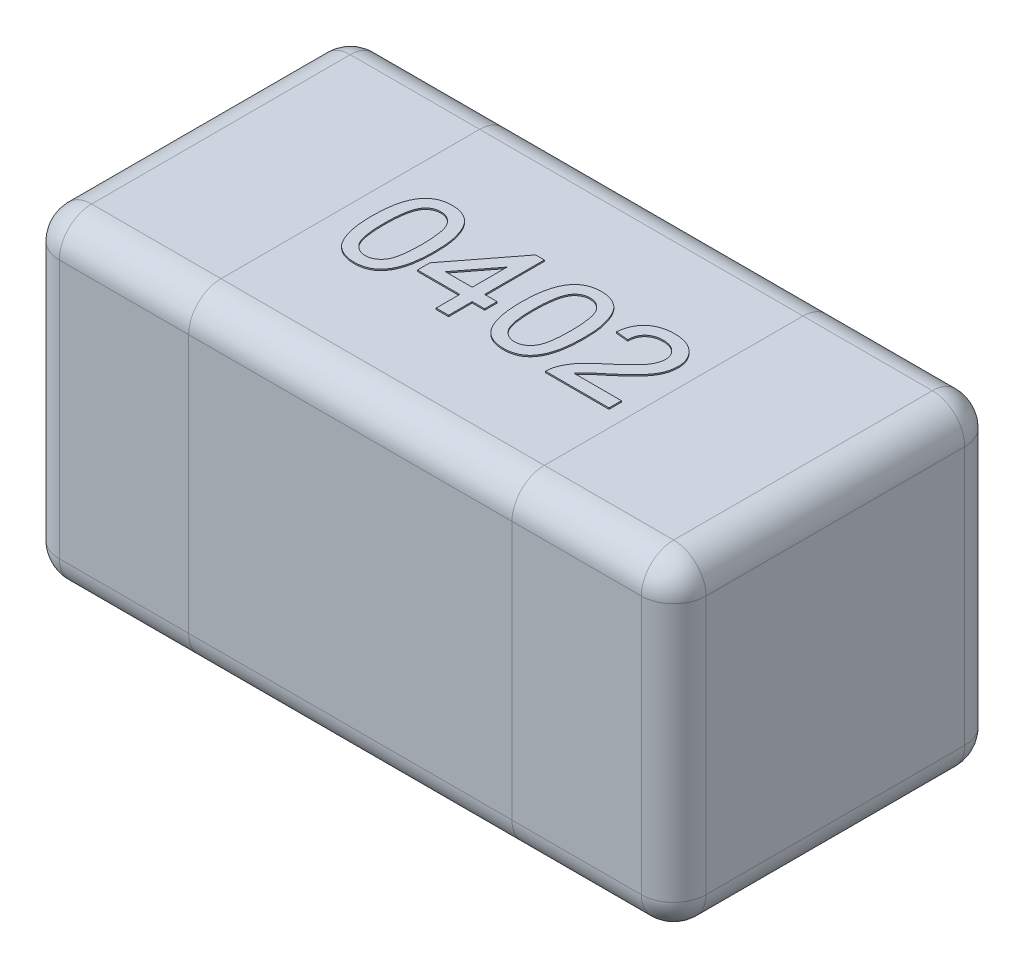
from build123d import *

# Parameters (mm, degrees)
SKETCH1_W      = 1
SKETCH1_H      = 0.5
EXTRUDE1_DEPTH = 0.5
FILLET1_R      = 0.05
EXTRUDE2_DEPTH = 0.002


with BuildPart() as part:
    # Sketch1 → Extrude1 (new body)
    with BuildSketch(Plane(origin=(0, 0, 0), x_dir=(1, 0, 0), z_dir=(0, 1, 0))):
        Rectangle(SKETCH1_W, SKETCH1_H)
    extrude(amount=EXTRUDE1_DEPTH)

    # Fillet1
    fillet1_edges = [part.edges().sort_by_distance(p)[0] for p in [
        (-0.5, 0.25, -0.25),
        (0.5, 0.25, -0.25),
        (0, 0, -0.25),
        (0, 0.5, -0.25),
        (0.5, 0.25, 0.25),
        (0.5, 0, 0),
        (0.5, 0.5, 0),
        (-0.5, 0.25, 0.25),
        (0, 0, 0.25),
        (0, 0.5, 0.25),
        (-0.5, 0, 0),
        (-0.5, 0.5, 0),
    ]]
    fillet(fillet1_edges, radius=FILLET1_R)

    # Sketch3 → Extrude2 (add)
    with BuildSketch(Plane(origin=(0, 0.5, 0), x_dir=(1, 0, 0), z_dir=(0, 1, 0))):
        with BuildLine():
            add(Edge.make_bspline(
                [(-0.215384615, -0.001021635), (-0.21536524, 0.001122003), (-0.215327293, 0.005320487), (-0.215091917, 0.011463622), (-0.21468097, 0.017297504), (-0.214067539, 0.022817065), (-0.213341122, 0.028034764), (-0.212396775, 0.032943155), (-0.211334247, 0.037553251), (-0.210059405, 0.041860246), (-0.20865877, 0.045901174), (-0.207069705, 0.04966955), (-0.205281792, 0.053161381), (-0.203382895, 0.056412877), (-0.201273053, 0.059373466), (-0.19907961, 0.062126232), (-0.196643162, 0.064570222), (-0.19406502, 0.06676832), (-0.191307221, 0.068708013), (-0.188384356, 0.070381735), (-0.185307672, 0.07185951), (-0.182018531, 0.072971978), (-0.178585214, 0.073878876), (-0.174981294, 0.074546001), (-0.171202799, 0.074939294), (-0.168620729, 0.074979536), (-0.167307692, 0.075)],
                knots=[0, 0, 0, 0, 6.431e-06, 1.2595e-05, 1.844e-05, 2.3971e-05, 2.9254e-05, 3.4239e-05, 3.8962e-05, 4.344e-05, 4.7707e-05, 5.1787e-05, 5.5698e-05, 5.947e-05, 6.3071e-05, 6.6596e-05, 7.0016e-05, 7.3406e-05, 7.6749e-05, 8.0114e-05, 8.3502e-05, 8.697e-05, 9.0512e-05, 9.4149e-05, 9.7955e-05, 0.000101893, 0.000101893, 0.000101893, 0.000101893], degree=3))
            add(Edge.make_bspline(
                [(-0.167307692, 0.075), (-0.165381297, 0.074943365), (-0.161596815, 0.074832104), (-0.156071453, 0.073924679), (-0.150864154, 0.072372388), (-0.145978304, 0.070278281), (-0.141497424, 0.067618363), (-0.137495809, 0.064384826), (-0.134016624, 0.060611623), (-0.131097837, 0.056254042), (-0.128546526, 0.051432296), (-0.126279998, 0.046124741), (-0.124231122, 0.040337325), (-0.122777195, 0.035156781), (-0.12174011, 0.030684751), (-0.121053643, 0.026996347), (-0.120483737, 0.023016538), (-0.120047112, 0.018754953), (-0.119688871, 0.014216372), (-0.119412219, 0.009397968), (-0.119271789, 0.004287698), (-0.119244699, 0.000781321), (-0.119230769, -0.001021635)],
                knots=[0, 0, 0, 0, 5.777e-06, 1.1349e-05, 1.674e-05, 2.2043e-05, 2.7258e-05, 3.2321e-05, 3.7425e-05, 4.2592e-05, 4.801e-05, 5.377e-05, 5.9891e-05, 6.6416e-05, 6.99e-05, 7.366e-05, 7.7668e-05, 8.1958e-05, 8.651e-05, 9.1325e-05, 9.6435e-05, 0.000101844, 0.000101844, 0.000101844, 0.000101844], degree=3))
            add(Edge.make_bspline(
                [(-0.119230769, -0.001021635), (-0.119250507, -0.003155203), (-0.119289069, -0.00732355), (-0.119518138, -0.013417428), (-0.119953848, -0.019207296), (-0.120489996, -0.024706416), (-0.121301077, -0.029900109), (-0.12217506, -0.034810441), (-0.123255962, -0.039415115), (-0.12451712, -0.043716149), (-0.12593747, -0.047736285), (-0.127495104, -0.051505906), (-0.129220334, -0.055022436), (-0.131164508, -0.058251575), (-0.133238671, -0.061236186), (-0.135458016, -0.063987464), (-0.137869594, -0.066465811), (-0.140470969, -0.068657315), (-0.143209405, -0.070631406), (-0.146139376, -0.072321652), (-0.149248057, -0.073721992), (-0.152514679, -0.074919212), (-0.155972386, -0.075796465), (-0.159593911, -0.076467989), (-0.163392598, -0.07686343), (-0.165984655, -0.07690292), (-0.167307692, -0.076923077)],
                knots=[0, 0, 0, 0, 6.401e-06, 1.2505e-05, 1.829e-05, 2.3818e-05, 2.9075e-05, 3.4055e-05, 3.8778e-05, 4.3256e-05, 4.7495e-05, 5.1563e-05, 5.5487e-05, 5.9233e-05, 6.2859e-05, 6.6384e-05, 6.9826e-05, 7.3215e-05, 7.6576e-05, 7.9941e-05, 8.3343e-05, 8.6794e-05, 9.0365e-05, 9.4031e-05, 9.7837e-05, 0.000101805, 0.000101805, 0.000101805, 0.000101805], degree=3))
            add(Edge.make_bspline(
                [(-0.167307692, -0.076923077), (-0.169042347, -0.076873596), (-0.172424447, -0.076777121), (-0.177363754, -0.076121636), (-0.181999557, -0.074967951), (-0.186370957, -0.073420697), (-0.190428817, -0.071351156), (-0.194192513, -0.068833154), (-0.197737673, -0.065925277), (-0.199778482, -0.063631029), (-0.200811298, -0.062469952)],
                knots=[0, 0, 0, 0, 5.204e-06, 1.0146e-05, 1.4912e-05, 1.9513e-05, 2.4028e-05, 2.8537e-05, 3.308e-05, 3.7736e-05, 3.7736e-05, 3.7736e-05, 3.7736e-05], degree=3))
            add(Edge.make_bspline(
                [(-0.200811298, -0.062469952), (-0.202000093, -0.060755098), (-0.204451439, -0.057218995), (-0.207320527, -0.051189611), (-0.209879805, -0.044552107), (-0.211888368, -0.037176254), (-0.213461574, -0.029120757), (-0.214597822, -0.020369808), (-0.215240826, -0.010927188), (-0.215335604, -0.004398023), (-0.215384615, -0.001021635)],
                knots=[0, 0, 0, 0, 6.251e-06, 1.2889e-05, 1.9965e-05, 2.7576e-05, 3.5785e-05, 4.4573e-05, 5.4032e-05, 6.4161e-05, 6.4161e-05, 6.4161e-05, 6.4161e-05], degree=3))
        make_face()
        with BuildLine():
            add(Edge.make_bspline(
                [(-0.196153846, -0.000961538), (-0.196134752, -0.003846584), (-0.1960982, -0.009369199), (-0.195716327, -0.017259208), (-0.195058949, -0.024377073), (-0.194189852, -0.030712939), (-0.193042293, -0.036275377), (-0.191601396, -0.041050211), (-0.189977162, -0.045094751), (-0.187967204, -0.048358867), (-0.185766521, -0.051019598), (-0.183494467, -0.053307912), (-0.181097587, -0.055252927), (-0.178591522, -0.056874673), (-0.175937387, -0.058102553), (-0.173164205, -0.058992522), (-0.170271373, -0.059504686), (-0.168301222, -0.059578275), (-0.167307692, -0.059615385)],
                knots=[0, 0, 0, 0, 8.655e-06, 1.6567e-05, 2.3689e-05, 3.0093e-05, 3.5745e-05, 4.0706e-05, 4.5043e-05, 4.8779e-05, 5.2153e-05, 5.5383e-05, 5.8438e-05, 6.1397e-05, 6.4314e-05, 6.7184e-05, 7.0113e-05, 7.3094e-05, 7.3094e-05, 7.3094e-05, 7.3094e-05], degree=3))
            add(Edge.make_bspline(
                [(-0.167307692, -0.059615385), (-0.166314411, -0.059577464), (-0.164344754, -0.059502268), (-0.161445238, -0.059001397), (-0.158682846, -0.058065613), (-0.156032668, -0.05684207), (-0.153508388, -0.055257289), (-0.15112328, -0.053304927), (-0.148839257, -0.051017971), (-0.14664846, -0.048326314), (-0.144653815, -0.045047107), (-0.142999112, -0.041005862), (-0.141580671, -0.036222665), (-0.140426814, -0.030663062), (-0.139554132, -0.024337213), (-0.138900728, -0.01723909), (-0.1385163, -0.009359233), (-0.138480352, -0.003846597), (-0.138461538, -0.000961538)],
                knots=[0, 0, 0, 0, 2.98e-06, 5.91e-06, 8.789e-06, 1.1706e-05, 1.4649e-05, 1.7704e-05, 2.0934e-05, 2.4331e-05, 2.8093e-05, 3.2402e-05, 3.7392e-05, 4.3044e-05, 4.9418e-05, 5.654e-05, 6.4422e-05, 7.3077e-05, 7.3077e-05, 7.3077e-05, 7.3077e-05], degree=3))
            add(Edge.make_bspline(
                [(-0.138461538, -0.000961538), (-0.13847975, 0.001863491), (-0.138514642, 0.007276142), (-0.138908985, 0.015014149), (-0.139526956, 0.022012544), (-0.140372243, 0.028277777), (-0.141495628, 0.033803048), (-0.142858142, 0.038600117), (-0.144481781, 0.042658756), (-0.146412281, 0.046019733), (-0.148561315, 0.048776646), (-0.150806184, 0.051162994), (-0.153203011, 0.053192505), (-0.15579426, 0.054820609), (-0.15849641, 0.056134103), (-0.161371551, 0.057038082), (-0.164391421, 0.057593459), (-0.166463918, 0.057658982), (-0.167518029, 0.057692308)],
                knots=[0, 0, 0, 0, 8.474e-06, 1.6237e-05, 2.3236e-05, 2.9547e-05, 3.5192e-05, 4.0137e-05, 4.4489e-05, 4.8272e-05, 5.1722e-05, 5.4953e-05, 5.8088e-05, 6.1114e-05, 6.4111e-05, 6.7076e-05, 7.0129e-05, 7.329e-05, 7.329e-05, 7.329e-05, 7.329e-05], degree=3))
            add(Edge.make_bspline(
                [(-0.167518029, 0.057692308), (-0.168511496, 0.057666233), (-0.170470487, 0.057614817), (-0.173338706, 0.057124054), (-0.176056884, 0.056303389), (-0.178656161, 0.055191718), (-0.181071649, 0.053695629), (-0.18339914, 0.051948838), (-0.185529622, 0.049820569), (-0.186813432, 0.048229508), (-0.187469952, 0.047415865)],
                knots=[0, 0, 0, 0, 2.979e-06, 5.873e-06, 8.697e-06, 1.1482e-05, 1.4327e-05, 1.72e-05, 2.0196e-05, 2.3331e-05, 2.3331e-05, 2.3331e-05, 2.3331e-05], degree=3))
            add(Edge.make_bspline(
                [(-0.187469952, 0.047415865), (-0.188184701, 0.046220876), (-0.189694102, 0.043697311), (-0.191383033, 0.03931125), (-0.192874969, 0.034298818), (-0.194103326, 0.028582894), (-0.194991956, 0.022173284), (-0.195693496, 0.01507743), (-0.196057919, 0.007285427), (-0.196120988, 0.001863295), (-0.196153846, -0.000961538)],
                knots=[0, 0, 0, 0, 4.171e-06, 8.807e-06, 1.4046e-05, 1.9857e-05, 2.6324e-05, 3.3449e-05, 4.1242e-05, 4.9717e-05, 4.9717e-05, 4.9717e-05, 4.9717e-05], degree=3))
        make_face(mode=Mode.SUBTRACT)
        Polygon((-0.042307692, -0.075), (-0.042307692, -0.038461538), (-0.107692308, -0.038461538), (-0.107692308, -0.019230769), (-0.036538462, 0.073076923), (-0.023076923, 0.073076923), (-0.023076923, -0.019230769), (-0.003846154, -0.019230769), (-0.003846154, -0.038461538), (-0.023076923, -0.038461538), (-0.023076923, -0.075), align=None)
        Polygon((-0.042307692, -0.019230769), (-0.042307692, 0.034795673), (-0.083954327, -0.019230769), align=None, mode=Mode.SUBTRACT)
        with BuildLine():
            add(Edge.make_bspline(
                [(0.015384615, -0.001021635), (0.01540399, 0.001122003), (0.015441938, 0.005320487), (0.015677314, 0.011463622), (0.016088261, 0.017297504), (0.016701692, 0.022817065), (0.017428109, 0.028034764), (0.018372456, 0.032943155), (0.019434984, 0.037553251), (0.020709826, 0.041860246), (0.022110461, 0.045901174), (0.023699525, 0.04966955), (0.025487439, 0.053161381), (0.027386336, 0.056412877), (0.029496178, 0.059373466), (0.031689621, 0.062126232), (0.034126069, 0.064570222), (0.036704211, 0.06676832), (0.03946201, 0.068708013), (0.042384875, 0.070381735), (0.045461558, 0.07185951), (0.0487507, 0.072971978), (0.052184016, 0.073878876), (0.055787937, 0.074546001), (0.059566432, 0.074939294), (0.062148502, 0.074979536), (0.063461538, 0.075)],
                knots=[0, 0, 0, 0, 6.431e-06, 1.2595e-05, 1.844e-05, 2.3971e-05, 2.9254e-05, 3.4239e-05, 3.8962e-05, 4.344e-05, 4.7707e-05, 5.1787e-05, 5.5698e-05, 5.947e-05, 6.3071e-05, 6.6596e-05, 7.0016e-05, 7.3406e-05, 7.6749e-05, 8.0114e-05, 8.3502e-05, 8.697e-05, 9.0512e-05, 9.4149e-05, 9.7955e-05, 0.000101893, 0.000101893, 0.000101893, 0.000101893], degree=3))
            add(Edge.make_bspline(
                [(0.063461538, 0.075), (0.065387934, 0.074943365), (0.069172416, 0.074832104), (0.074697778, 0.073924679), (0.079905076, 0.072372388), (0.084790927, 0.070278281), (0.089271807, 0.067618363), (0.093273422, 0.064384826), (0.096752607, 0.060611623), (0.099671394, 0.056254042), (0.102222704, 0.051432296), (0.104489233, 0.046124741), (0.106538109, 0.040337325), (0.107992036, 0.035156781), (0.10902912, 0.030684751), (0.109715588, 0.026996347), (0.110285494, 0.023016538), (0.110722119, 0.018754953), (0.111080359, 0.014216372), (0.111357012, 0.009397968), (0.111497442, 0.004287698), (0.111524532, 0.000781321), (0.111538462, -0.001021635)],
                knots=[0, 0, 0, 0, 5.777e-06, 1.1349e-05, 1.674e-05, 2.2043e-05, 2.7258e-05, 3.2321e-05, 3.7425e-05, 4.2592e-05, 4.801e-05, 5.377e-05, 5.9891e-05, 6.6416e-05, 6.99e-05, 7.366e-05, 7.7668e-05, 8.1958e-05, 8.651e-05, 9.1325e-05, 9.6435e-05, 0.000101844, 0.000101844, 0.000101844, 0.000101844], degree=3))
            add(Edge.make_bspline(
                [(0.111538462, -0.001021635), (0.111518724, -0.003155203), (0.111480162, -0.00732355), (0.111251093, -0.013417428), (0.110815383, -0.019207296), (0.110279235, -0.024706416), (0.109468154, -0.029900109), (0.108594171, -0.034810441), (0.107513269, -0.039415115), (0.106252111, -0.043716149), (0.10483176, -0.047736285), (0.103274126, -0.051505906), (0.101548897, -0.055022436), (0.099604723, -0.058251575), (0.097530559, -0.061236186), (0.095311215, -0.063987464), (0.092899636, -0.066465811), (0.090298262, -0.068657315), (0.087559826, -0.070631406), (0.084629855, -0.072321652), (0.081521174, -0.073721992), (0.078254552, -0.074919212), (0.074796845, -0.075796465), (0.07117532, -0.076467989), (0.067376633, -0.07686343), (0.064784575, -0.07690292), (0.063461538, -0.076923077)],
                knots=[0, 0, 0, 0, 6.401e-06, 1.2505e-05, 1.829e-05, 2.3818e-05, 2.9075e-05, 3.4055e-05, 3.8778e-05, 4.3256e-05, 4.7495e-05, 5.1563e-05, 5.5487e-05, 5.9233e-05, 6.2859e-05, 6.6384e-05, 6.9826e-05, 7.3215e-05, 7.6576e-05, 7.9941e-05, 8.3343e-05, 8.6794e-05, 9.0365e-05, 9.4031e-05, 9.7837e-05, 0.000101805, 0.000101805, 0.000101805, 0.000101805], degree=3))
            add(Edge.make_bspline(
                [(0.063461538, -0.076923077), (0.061726884, -0.076873596), (0.058344784, -0.076777121), (0.053405477, -0.076121636), (0.048769674, -0.074967951), (0.044398274, -0.073420697), (0.040340414, -0.071351156), (0.036576718, -0.068833154), (0.033031558, -0.065925277), (0.030990749, -0.063631029), (0.029957933, -0.062469952)],
                knots=[0, 0, 0, 0, 5.204e-06, 1.0146e-05, 1.4912e-05, 1.9513e-05, 2.4028e-05, 2.8537e-05, 3.308e-05, 3.7736e-05, 3.7736e-05, 3.7736e-05, 3.7736e-05], degree=3))
            add(Edge.make_bspline(
                [(0.029957933, -0.062469952), (0.028769138, -0.060755098), (0.026317792, -0.057218995), (0.023448703, -0.051189611), (0.020889426, -0.044552107), (0.018880862, -0.037176254), (0.017307656, -0.029120757), (0.016171409, -0.020369808), (0.015528405, -0.010927188), (0.015433627, -0.004398023), (0.015384615, -0.001021635)],
                knots=[0, 0, 0, 0, 6.251e-06, 1.2889e-05, 1.9965e-05, 2.7576e-05, 3.5785e-05, 4.4573e-05, 5.4032e-05, 6.4161e-05, 6.4161e-05, 6.4161e-05, 6.4161e-05], degree=3))
        make_face()
        with BuildLine():
            add(Edge.make_bspline(
                [(0.034615385, -0.000961538), (0.034634479, -0.003846584), (0.034671031, -0.009369199), (0.035052903, -0.017259208), (0.035710281, -0.024377073), (0.036579378, -0.030712939), (0.037726938, -0.036275377), (0.039167835, -0.041050211), (0.040792069, -0.045094751), (0.042802027, -0.048358867), (0.04500271, -0.051019598), (0.047274764, -0.053307912), (0.049671644, -0.055252927), (0.052177709, -0.056874673), (0.054831844, -0.058102553), (0.057605026, -0.058992522), (0.060497858, -0.059504686), (0.062468008, -0.059578275), (0.063461538, -0.059615385)],
                knots=[0, 0, 0, 0, 8.655e-06, 1.6567e-05, 2.3689e-05, 3.0093e-05, 3.5745e-05, 4.0706e-05, 4.5043e-05, 4.8779e-05, 5.2153e-05, 5.5383e-05, 5.8438e-05, 6.1397e-05, 6.4314e-05, 6.7184e-05, 7.0113e-05, 7.3094e-05, 7.3094e-05, 7.3094e-05, 7.3094e-05], degree=3))
            add(Edge.make_bspline(
                [(0.063461538, -0.059615385), (0.06445482, -0.059577464), (0.066424477, -0.059502268), (0.069323993, -0.059001397), (0.072086385, -0.058065613), (0.074736563, -0.05684207), (0.077260843, -0.055257289), (0.079645951, -0.053304927), (0.081929974, -0.051017971), (0.084120771, -0.048326314), (0.086115416, -0.045047107), (0.087770119, -0.041005862), (0.08918856, -0.036222665), (0.090342417, -0.030663062), (0.091215099, -0.024337213), (0.091868502, -0.01723909), (0.092252931, -0.009359233), (0.092288879, -0.003846597), (0.092307692, -0.000961538)],
                knots=[0, 0, 0, 0, 2.98e-06, 5.91e-06, 8.789e-06, 1.1706e-05, 1.4649e-05, 1.7704e-05, 2.0934e-05, 2.4331e-05, 2.8093e-05, 3.2402e-05, 3.7392e-05, 4.3044e-05, 4.9418e-05, 5.654e-05, 6.4422e-05, 7.3077e-05, 7.3077e-05, 7.3077e-05, 7.3077e-05], degree=3))
            add(Edge.make_bspline(
                [(0.092307692, -0.000961538), (0.092289481, 0.001863491), (0.092254589, 0.007276142), (0.091860246, 0.015014149), (0.091242275, 0.022012544), (0.090396988, 0.028277777), (0.089273602, 0.033803048), (0.087911089, 0.038600117), (0.08628745, 0.042658756), (0.084356949, 0.046019733), (0.082207916, 0.048776646), (0.079963047, 0.051162994), (0.07756622, 0.053192505), (0.074974971, 0.054820609), (0.07227282, 0.056134103), (0.06939768, 0.057038082), (0.06637781, 0.057593459), (0.064305312, 0.057658982), (0.063251202, 0.057692308)],
                knots=[0, 0, 0, 0, 8.474e-06, 1.6237e-05, 2.3236e-05, 2.9547e-05, 3.5192e-05, 4.0137e-05, 4.4489e-05, 4.8272e-05, 5.1722e-05, 5.4953e-05, 5.8088e-05, 6.1114e-05, 6.4111e-05, 6.7076e-05, 7.0129e-05, 7.329e-05, 7.329e-05, 7.329e-05, 7.329e-05], degree=3))
            add(Edge.make_bspline(
                [(0.063251202, 0.057692308), (0.062257734, 0.057666233), (0.060298744, 0.057614817), (0.057430524, 0.057124054), (0.054712347, 0.056303389), (0.052113069, 0.055191718), (0.049697582, 0.053695629), (0.047370091, 0.051948838), (0.045239608, 0.049820569), (0.043955798, 0.048229508), (0.043299279, 0.047415865)],
                knots=[0, 0, 0, 0, 2.979e-06, 5.873e-06, 8.697e-06, 1.1482e-05, 1.4327e-05, 1.72e-05, 2.0196e-05, 2.3331e-05, 2.3331e-05, 2.3331e-05, 2.3331e-05], degree=3))
            add(Edge.make_bspline(
                [(0.043299279, 0.047415865), (0.042584529, 0.046220876), (0.041075129, 0.043697311), (0.039386197, 0.03931125), (0.037894262, 0.034298818), (0.036665905, 0.028582894), (0.035777274, 0.022173284), (0.035075735, 0.01507743), (0.034711312, 0.007285427), (0.034648242, 0.001863295), (0.034615385, -0.000961538)],
                knots=[0, 0, 0, 0, 4.171e-06, 8.807e-06, 1.4046e-05, 1.9857e-05, 2.6324e-05, 3.3449e-05, 4.1242e-05, 4.9717e-05, 4.9717e-05, 4.9717e-05, 4.9717e-05], degree=3))
        make_face(mode=Mode.SUBTRACT)
        with BuildLine():
            Line((0.225, -0.055769231), (0.225, -0.075))
            Line((0.225, -0.075), (0.126923077, -0.075))
            add(Edge.make_bspline(
                [(0.126923077, -0.075), (0.126921069, -0.073857061), (0.12691706, -0.071575015), (0.127303219, -0.068200013), (0.127908021, -0.064869783), (0.128591871, -0.062734239), (0.128936298, -0.061658654)],
                knots=[0, 0, 0, 0, 3.426e-06, 6.841e-06, 1.0176e-05, 1.3561e-05, 1.3561e-05, 1.3561e-05, 1.3561e-05], degree=3))
            add(Edge.make_bspline(
                [(0.128936298, -0.061658654), (0.129572684, -0.059901276), (0.130868472, -0.056322964), (0.133493751, -0.051159961), (0.136581699, -0.046028182), (0.139588252, -0.04185019), (0.142341605, -0.038512266), (0.14465065, -0.035900727), (0.147209495, -0.033227509), (0.150016092, -0.030493101), (0.153043427, -0.027679792), (0.156295632, -0.0247782), (0.159811111, -0.021842401), (0.162265283, -0.019896431), (0.163521635, -0.01890024)],
                knots=[0, 0, 0, 0, 5.603e-06, 1.1408e-05, 1.7339e-05, 2.356e-05, 2.6827e-05, 3.0318e-05, 3.4016e-05, 3.7925e-05, 4.2071e-05, 4.6413e-05, 5.0999e-05, 5.5809e-05, 5.5809e-05, 5.5809e-05, 5.5809e-05], degree=3))
            add(Edge.make_bspline(
                [(0.163521635, -0.01890024), (0.1654517, -0.017275735), (0.169168165, -0.014147648), (0.174416395, -0.009505855), (0.179209799, -0.005195689), (0.183472047, -0.001141602), (0.187238, 0.002617081), (0.1905165, 0.006071846), (0.193335758, 0.009211911), (0.195661355, 0.012150933), (0.197623532, 0.014926186), (0.199286304, 0.017633275), (0.200672004, 0.020319486), (0.201826106, 0.022976319), (0.202738903, 0.025615135), (0.203361104, 0.028243623), (0.203783059, 0.030835702), (0.203825276, 0.0325605), (0.203846154, 0.033413462)],
                knots=[0, 0, 0, 0, 7.568e-06, 1.4572e-05, 2.1018e-05, 2.6906e-05, 3.2217e-05, 3.6978e-05, 4.1193e-05, 4.4872e-05, 4.8215e-05, 5.1384e-05, 5.4395e-05, 5.7275e-05, 6.0069e-05, 6.2758e-05, 6.5371e-05, 6.7928e-05, 6.7928e-05, 6.7928e-05, 6.7928e-05], degree=3))
            add(Edge.make_bspline(
                [(0.203846154, 0.033413462), (0.203825274, 0.034256471), (0.203784308, 0.035910411), (0.20339563, 0.03833094), (0.202854559, 0.040661969), (0.201979812, 0.042861531), (0.2009386, 0.044994766), (0.199602994, 0.046994266), (0.198057972, 0.048909863), (0.196289053, 0.050691052), (0.194356979, 0.052362092), (0.192198162, 0.053751132), (0.189954391, 0.055001681), (0.18754826, 0.056007195), (0.184983678, 0.056745562), (0.182279313, 0.057281426), (0.179435596, 0.057621193), (0.177494958, 0.057668243), (0.176502404, 0.057692308)],
                knots=[0, 0, 0, 0, 2.527e-06, 4.958e-06, 7.341e-06, 9.69e-06, 1.2042e-05, 1.445e-05, 1.6886e-05, 1.9414e-05, 2.1973e-05, 2.4531e-05, 2.71e-05, 2.9672e-05, 3.2335e-05, 3.5092e-05, 3.7936e-05, 4.0913e-05, 4.0913e-05, 4.0913e-05, 4.0913e-05], degree=3))
            add(Edge.make_bspline(
                [(0.176502404, 0.057692308), (0.175459753, 0.057668362), (0.173419208, 0.0576215), (0.170436479, 0.057280378), (0.167604894, 0.05675919), (0.164931212, 0.055962339), (0.162418689, 0.054958502), (0.160077555, 0.053694939), (0.157870321, 0.052268604), (0.155866501, 0.050579931), (0.154054473, 0.048707538), (0.152445813, 0.046669068), (0.151127759, 0.044425183), (0.150039255, 0.042025221), (0.149164007, 0.039461638), (0.148528606, 0.036714835), (0.148182182, 0.033792744), (0.148112518, 0.031791696), (0.148076923, 0.030769231)],
                knots=[0, 0, 0, 0, 3.127e-06, 6.12e-06, 8.996e-06, 1.1753e-05, 1.4476e-05, 1.7098e-05, 1.9723e-05, 2.2347e-05, 2.4939e-05, 2.753e-05, 3.0117e-05, 3.2725e-05, 3.5424e-05, 3.823e-05, 4.1167e-05, 4.4236e-05, 4.4236e-05, 4.4236e-05, 4.4236e-05], degree=3))
            Line((0.148076923, 0.030769231), (0.128846154, 0.032692308))
            add(Edge.make_bspline(
                [(0.128846154, 0.032692308), (0.129042912, 0.034368316), (0.129425688, 0.037628847), (0.13037913, 0.042351176), (0.131717678, 0.046744295), (0.133319362, 0.050869455), (0.135327225, 0.054656431), (0.137596941, 0.058183555), (0.140273966, 0.06133896), (0.143231368, 0.064222108), (0.14650155, 0.066762921), (0.150053792, 0.068982673), (0.15388647, 0.070839359), (0.157978237, 0.072376617), (0.162338487, 0.073542974), (0.166961051, 0.074379362), (0.171853364, 0.074894921), (0.17520906, 0.074964474), (0.176923077, 0.075)],
                knots=[0, 0, 0, 0, 5.061e-06, 9.846e-06, 1.4428e-05, 1.8825e-05, 2.3099e-05, 2.7266e-05, 3.1383e-05, 3.5484e-05, 3.9638e-05, 4.3781e-05, 4.8028e-05, 5.2392e-05, 5.6875e-05, 6.1549e-05, 6.6473e-05, 7.1615e-05, 7.1615e-05, 7.1615e-05, 7.1615e-05], degree=3))
            add(Edge.make_bspline(
                [(0.176923077, 0.075), (0.178657609, 0.074970298), (0.182036489, 0.074912439), (0.186960059, 0.07432042), (0.191605584, 0.073398356), (0.195990093, 0.072113282), (0.200087683, 0.070428166), (0.203901505, 0.068369335), (0.207449145, 0.065956873), (0.210671327, 0.063161818), (0.213576854, 0.060110548), (0.216123119, 0.056854184), (0.21825192, 0.053406639), (0.220064461, 0.049814905), (0.22140889, 0.046003091), (0.222354317, 0.042023019), (0.222996763, 0.037871287), (0.223049848, 0.035038552), (0.223076923, 0.03359375)],
                knots=[0, 0, 0, 0, 5.201e-06, 1.0132e-05, 1.4853e-05, 1.9397e-05, 2.3817e-05, 2.8119e-05, 3.2378e-05, 3.666e-05, 4.089e-05, 4.5001e-05, 4.9037e-05, 5.3028e-05, 5.7048e-05, 6.1129e-05, 6.5289e-05, 6.962e-05, 6.962e-05, 6.962e-05, 6.962e-05], degree=3))
            add(Edge.make_bspline(
                [(0.223076923, 0.03359375), (0.223035579, 0.03210938), (0.222952801, 0.029137364), (0.222306703, 0.024695077), (0.221201221, 0.020300998), (0.219735648, 0.01590165), (0.21773337, 0.011479571), (0.215203832, 0.006973759), (0.212065664, 0.002367569), (0.209047626, -0.001548204), (0.206238322, -0.00483061), (0.20374814, -0.007532221), (0.200867143, -0.010402503), (0.197703409, -0.013540859), (0.194127905, -0.016835902), (0.190243364, -0.020386306), (0.185964751, -0.024098636), (0.18299456, -0.026634721), (0.181460337, -0.027944712)],
                knots=[0, 0, 0, 0, 4.452e-06, 8.914e-06, 1.3432e-05, 1.8031e-05, 2.2806e-05, 2.7972e-05, 3.3514e-05, 3.9512e-05, 4.2794e-05, 4.6473e-05, 5.0531e-05, 5.4993e-05, 5.9841e-05, 6.5116e-05, 7.0781e-05, 7.6833e-05, 7.6833e-05, 7.6833e-05, 7.6833e-05], degree=3))
            add(Edge.make_bspline(
                [(0.181460337, -0.027944712), (0.180146506, -0.02901431), (0.177641234, -0.031053868), (0.174076998, -0.034010672), (0.170884527, -0.03672198), (0.167989166, -0.039099356), (0.16549636, -0.04125779), (0.163318306, -0.043102752), (0.161534132, -0.044727006), (0.158817151, -0.047194282), (0.155375862, -0.050711133), (0.152840174, -0.05412836), (0.151622596, -0.055769231)],
                knots=[0, 0, 0, 0, 5.082e-06, 9.692e-06, 1.3893e-05, 1.7648e-05, 2.093e-05, 2.3785e-05, 2.621e-05, 2.8167e-05, 3.4797e-05, 4.0922e-05, 4.0922e-05, 4.0922e-05, 4.0922e-05], degree=3))
            Line((0.151622596, -0.055769231), (0.225, -0.055769231))
        make_face()
    extrude(amount=EXTRUDE2_DEPTH)


solid = part.part
